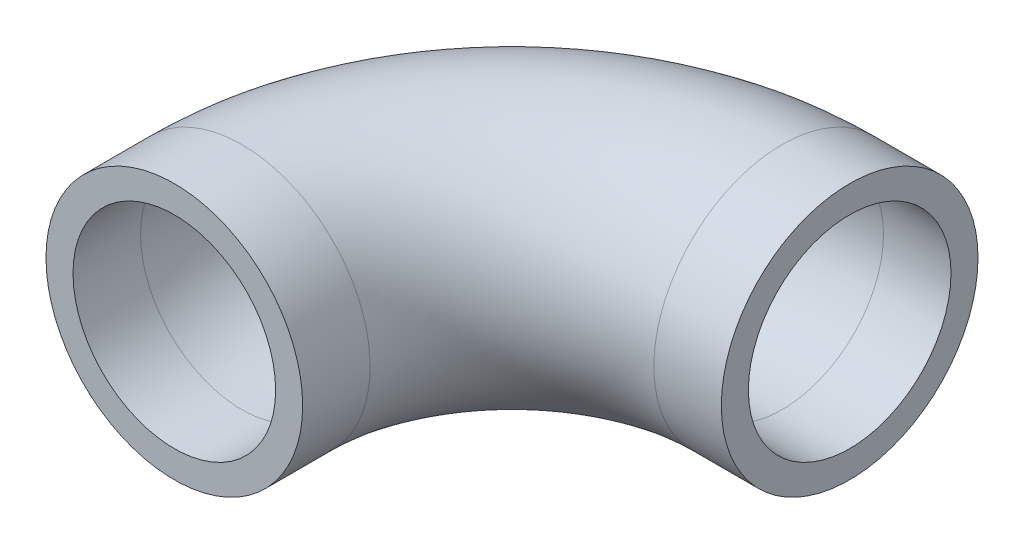
from build123d import *

# Parameters (mm, degrees)
SKETCH1_R   = 24.13
SKETCH1_R_2 = 19.05


with BuildPart() as part:
    # Sweep1: sweep along a path in Sketch15
    with BuildLine(Plane(origin=(0, 0, 0), x_dir=(1, 0, 0), z_dir=(0, 1, 0))) as sweep1_path:
        Line((0, 0), (0, 12.7))
        ThreePointArc((0, 12.7), (14.878975516, 48.621024484), (50.8, 63.5))
        Line((50.8, 63.5), (63.5, 63.5))
    # Sketch1 → Sweep1 (sweep)
    with BuildSketch(Plane.XY):
        Circle(SKETCH1_R)
        Circle(SKETCH1_R_2, mode=Mode.SUBTRACT)
    sweep(path=sweep1_path.line)


solid = part.part
